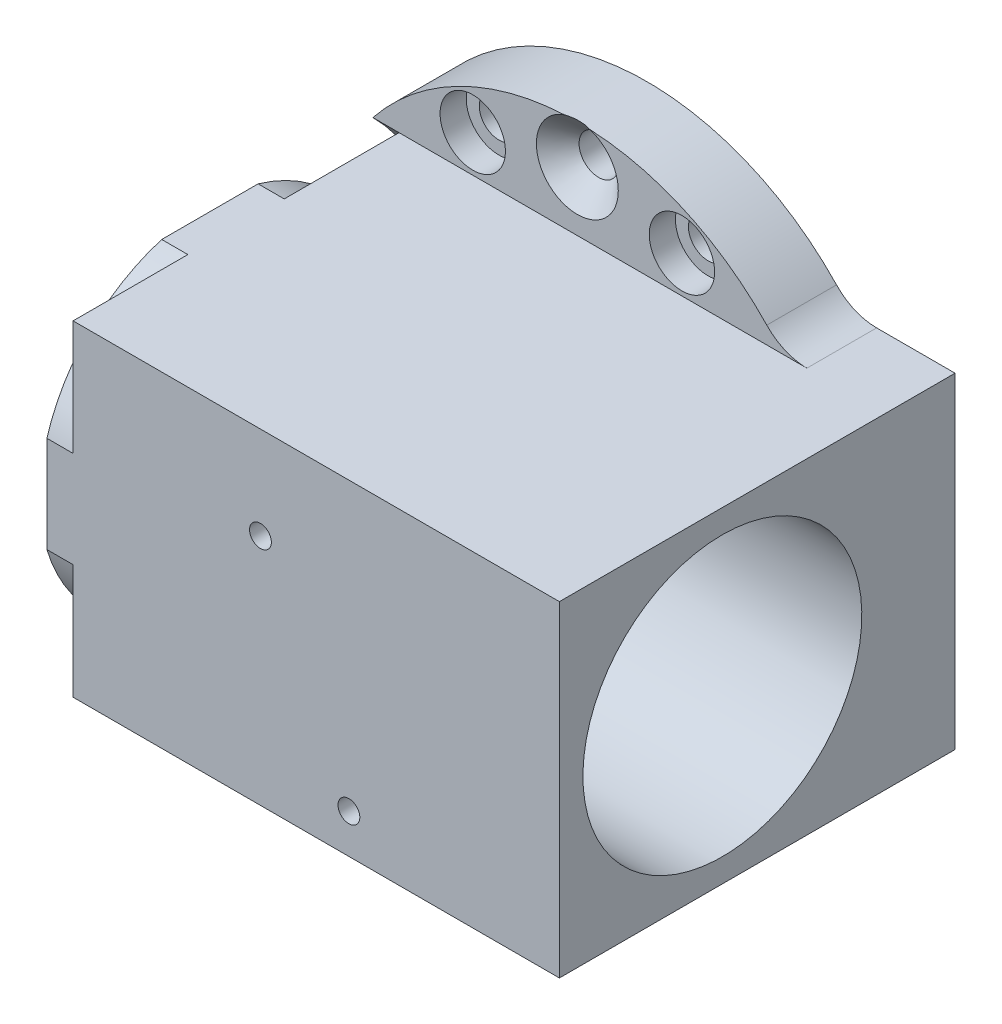
from build123d import *

# Parameters (mm, degrees)
BOSS_EXTRUDE1_DEPTH                                 = 8
CUT_EXTRUDE1_REACH                                  = 5
SKETCH4_W                                           = 55.8
SKETCH4_H                                           = 37.4
BOSS_EXTRUDE2_DEPTH                                 = 37.4
BOSS_EXTRUDE3_DEPTH                                 = 3
CUT_EXTRUDE2_DEPTH                                  = 3
CUT_EXTRUDE3_DEPTH                                  = 3
CSK_FOR_8_FLAT_HEAD_MACHINE_SCREW_100_D             = 4.5
CSK_FOR_8_FLAT_HEAD_MACHINE_SCREW_100_DEPTH         = 8
CSK_FOR_8_FLAT_HEAD_MACHINE_SCREW_100_CSINK_D       = 9.4
CSK_FOR_8_FLAT_HEAD_MACHINE_SCREW_100_CSINK_ANGLE   = 90
F_4_CLEARANCE_HOLE1_D                               = 3.3
F_4_CLEARANCE_HOLE1_DEPTH                           = 6
CBORE_FOR_8_BINDING_HEAD_MACHINE_SCREW1_D           = 4.5
CBORE_FOR_8_BINDING_HEAD_MACHINE_SCREW1_DEPTH       = 8
CBORE_FOR_8_BINDING_HEAD_MACHINE_SCREW1_CBORE_D     = 7.5
CBORE_FOR_8_BINDING_HEAD_MACHINE_SCREW1_CBORE_DEPTH = 3
FILLET1_R                                           = 6.35
M3X0_5_TAPPED_HOLE1_D                               = 2.5
M3X0_5_TAPPED_HOLE1_DEPTH                           = 4
M3X0_5_TAPPED_HOLE1_TIP                             = 0.751075774
FILLET2_R                                           = 6.35
SKETCH_1_R                                          = 16
CUT_EXTRUDE_1_DEPTH                                 = 25.4
SKETCH_2_R                                          = 16
CUT_EXTRUDE_2_DEPTH                                 = 25.4
SKETCH_3_R                                          = 13.55
CUT_EXTRUDE_3_DEPTH                                 = 10


with BuildPart() as part:
    # Sketch1 → Boss-Extrude1 (new body)
    with BuildSketch(Plane.XY.offset(8)):
        with BuildLine():
            Line((-23.45868709, 18.7), (-23.45868709, -18.7))
            ThreePointArc((-23.45868709, -18.7), (0, -30), (23.45868709, -18.7))
            Line((23.45868709, -18.7), (35.34131291, -18.7))
            Line((35.34131291, -18.7), (35.34131291, 18.7))
            Line((35.34131291, 18.7), (23.45868709, 18.7))
            ThreePointArc((23.45868709, 18.7), (0, 30), (-23.45868709, 18.7))
        make_face()
    extrude(amount=-BOSS_EXTRUDE1_DEPTH)

    # Sketch3 → Cut-Extrude1 (cut, up to next)
    with BuildSketch(Plane(origin=(-20.45868709, 0, 0), x_dir=(0, 0, -1), z_dir=(1, 0, 0)), mode=Mode.PRIVATE) as cut_extrude1_sk1:
        with BuildLine():
            Line((-8, 18.7), (-8, -18.7))
            ThreePointArc((-8, -18.7), (-0.254206384, 0), (-8, 18.7))
        make_face()
    cut_extrude1_tool1 = extrude(cut_extrude1_sk1.sketch, amount=-CUT_EXTRUDE1_REACH, mode=Mode.PRIVATE) & part.part
    add(cut_extrude1_tool1.solids().sort_by_distance((-20.458687, 0, 4.859168))[0], mode=Mode.SUBTRACT)

    # Sketch4 → Boss-Extrude2 (add)
    with BuildSketch(Plane.XY.offset(8)):
        with Locations((7.44131291, 0)):
            Rectangle(SKETCH4_W, SKETCH4_H)
    extrude(amount=BOSS_EXTRUDE2_DEPTH)

    # Sketch5 → Boss-Extrude3 (add)
    with BuildSketch(Plane.ZY.offset(20.45868709)):
        with BuildLine():
            Line((21.171890016, 18.7), (45.4, 18.7))
            Line((45.4, 18.7), (45.4, -18.7))
            Line((45.4, -18.7), (21.171890016, -18.7))
            ThreePointArc((21.171890016, -18.7), (7.2, 0), (21.171890016, 18.7))
        make_face()
    extrude(amount=BOSS_EXTRUDE3_DEPTH)

    # Sketch6 → Cut-Extrude2 (cut)
    with BuildSketch(Plane.ZY.offset(23.45868709)):
        with BuildLine():
            Line((45.4, -18.7), (45.4, -5.528109984))
            ThreePointArc((45.4, -5.528109984), (40.488582233, -13.788582233), (32.228109984, -18.7))
            Line((32.228109984, -18.7), (45.4, -18.7))
        make_face()
    extrude(amount=-CUT_EXTRUDE2_DEPTH, mode=Mode.SUBTRACT)

    # Sketch7 → Cut-Extrude3 (cut)
    with BuildSketch(Plane.ZY.offset(23.45868709)):
        with BuildLine():
            Line((45.4, 18.7), (32.228109984, 18.7))
            ThreePointArc((32.228109984, 18.7), (40.488582233, 13.788582233), (45.4, 5.528109984))
            Line((45.4, 5.528109984), (45.4, 18.7))
        make_face()
    extrude(amount=-CUT_EXTRUDE3_DEPTH, mode=Mode.SUBTRACT)

    # Sketch8 → Cut-Revolve1 (revolve, cut)
    with BuildSketch(Plane.XY.offset(26.7)):
        Polygon((-23.45868709, 15.86865), (-23.45868709, 0), (35.34131291, 0), (35.34131291, 15.86865), (9.94131291, 15.86865), (9.94131291, 13.5), (1.94131291, 13.5), (1.94131291, 15.86865), align=None)
    revolve(axis=Axis((-23.45868709, 0, 26.7), (1, 0, 0)), mode=Mode.SUBTRACT)

    # CSK for #8 Flat Head Machine Screw (100)1
    with Locations(Plane.XY.offset(8)):
        with Locations((0, 25.5), (0, -25.5)):
            CounterSinkHole(CSK_FOR_8_FLAT_HEAD_MACHINE_SCREW_100_D / 2, CSK_FOR_8_FLAT_HEAD_MACHINE_SCREW_100_CSINK_D / 2, depth=CSK_FOR_8_FLAT_HEAD_MACHINE_SCREW_100_DEPTH, counter_sink_angle=CSK_FOR_8_FLAT_HEAD_MACHINE_SCREW_100_CSINK_ANGLE)

    # #4 Clearance Hole1
    with Locations(Plane(origin=(0, -18.7, 0), x_dir=(-1, 0, 0), z_dir=(0, -1, 0))):
        with Locations((12.45868709, -39.4), (-29.44131291, -39.4), (-29.44131291, -5.9)):
            Hole(F_4_CLEARANCE_HOLE1_D / 2, depth=F_4_CLEARANCE_HOLE1_DEPTH)

    # CBORE for #8 Binding Head Machine Screw1
    with Locations(Plane.XY.offset(8)):
        with Locations((12, 22.95), (-12, 22.95), (-12, -22.95), (12, -22.95)):
            CounterBoreHole(CBORE_FOR_8_BINDING_HEAD_MACHINE_SCREW1_D / 2, CBORE_FOR_8_BINDING_HEAD_MACHINE_SCREW1_CBORE_D / 2, CBORE_FOR_8_BINDING_HEAD_MACHINE_SCREW1_CBORE_DEPTH, depth=CBORE_FOR_8_BINDING_HEAD_MACHINE_SCREW1_DEPTH)

    # Fillet1
    fillet1_edges = [part.edges().sort_by_distance(p)[0] for p in [
        (23.45868709, 18.7, 4),
    ]]
    fillet(fillet1_edges, radius=FILLET1_R)

    # M3x0.5 Tapped Hole1
    with Locations(Plane(origin=(1.04131291, 8.07366885, 45.4), x_dir=(1, 0, 0), z_dir=(0, 0, 1))):
        with Locations((0, 0), (10.150400418, -22.272670952)):
            Hole(M3X0_5_TAPPED_HOLE1_D / 2, depth=M3X0_5_TAPPED_HOLE1_DEPTH)
            with Locations((0, 0, -(M3X0_5_TAPPED_HOLE1_DEPTH + M3X0_5_TAPPED_HOLE1_TIP / 2))):  # 118° drill point
                Cone(0, M3X0_5_TAPPED_HOLE1_D / 2, M3X0_5_TAPPED_HOLE1_TIP, mode=Mode.SUBTRACT)

    # Fillet2
    fillet2_edges = [part.edges().sort_by_distance(p)[0] for p in [
        (23.45868709, -18.7, 4),
    ]]
    fillet(fillet2_edges, radius=FILLET2_R)

    # 草图1 → 切除-拉伸1 (cut)
    with BuildSketch(Plane(origin=(35.34131291, 0, 0), x_dir=(0, 0, -1), z_dir=(1, 0, 0))):
        with Locations((-26.7, 0)):
            Circle(SKETCH_1_R)
    extrude(amount=-CUT_EXTRUDE_1_DEPTH, mode=Mode.SUBTRACT)

    # 草图2 → 切除-拉伸2 (cut)
    with BuildSketch(Plane.ZY.offset(23.45868709)):
        with Locations((26.7, 0)):
            Circle(SKETCH_2_R)
    extrude(amount=-CUT_EXTRUDE_2_DEPTH, mode=Mode.SUBTRACT)

    # 草图3 → 切除-拉伸3 (cut)
    with BuildSketch(Plane.ZY.offset(-1.94131291)):
        with Locations((26.7, 0)):
            Circle(SKETCH_3_R)
    extrude(amount=-CUT_EXTRUDE_3_DEPTH, mode=Mode.SUBTRACT)


solid = part.part
